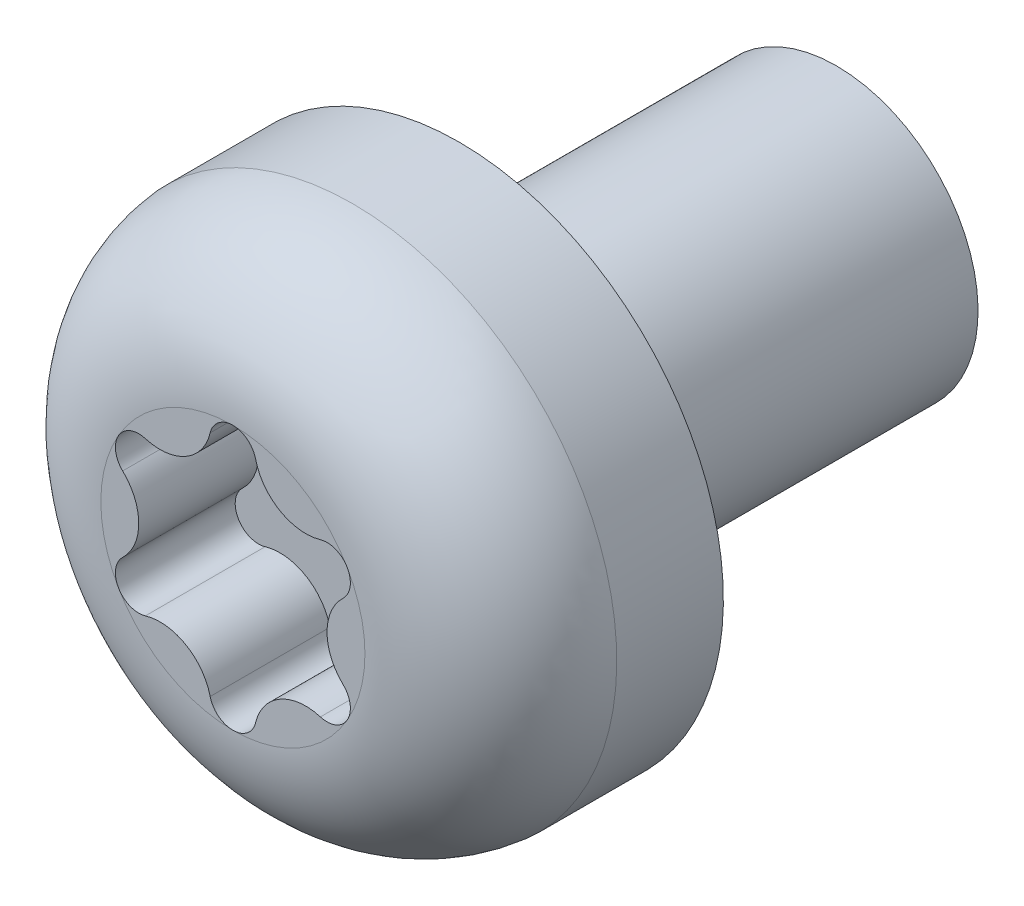
from build123d import *

# Parameters (mm, degrees)
ENL_V_MAT_EXTRU_1_DEPTH = 1.27


with BuildPart() as part:
    # Esquisse1 → Révolution1 (revolve)
    with BuildSketch(Plane(origin=(0, 0, 0), x_dir=(0, 0, -1), z_dir=(1, 0, 0))):
        with BuildLine():
            Line((-2.4, 0), (-2.4, 1.4))
            ThreePointArc((-2.4, 1.4), (-2.035195386, 2.345105814), (-1.13, 2.8))
            Line((-1.13, 2.8), (0, 2.8))
            Line((0, 2.8), (0, 1.5))
            Line((0, 1.5), (4, 1.5))
            Line((4, 1.5), (4, 0))
            Line((4, 0), (-2.4, 0))
        make_face()
    revolve(axis=Axis((0, 0, 2.4), (0, 0, 1)))

    # Esquisse2 → Enlèv. mat.-Extru.1 (cut)
    with BuildSketch(Plane.XY.offset(2.4)):
        with BuildLine():
            ThreePointArc((-0.240728142, 1.210222096), (0, 1.4), (0.240728142, 1.210222096))
            ThreePointArc((0.240728142, 1.210222096), (0.499017901, 0.864324358), (0.927719008, 0.813587734))
            ThreePointArc((0.927719008, 0.813587734), (1.212435565, 0.7), (1.16844715, 0.396634361))
            ThreePointArc((1.16844715, 0.396634361), (0.998035801, 0), (1.16844715, -0.396634361))
            ThreePointArc((1.16844715, -0.396634361), (1.212435565, -0.7), (0.927719008, -0.813587734))
            ThreePointArc((0.927719008, -0.813587734), (0.499017901, -0.864324358), (0.240728142, -1.210222096))
            ThreePointArc((0.240728142, -1.210222096), (0, -1.4), (-0.240728142, -1.210222096))
            ThreePointArc((-0.240728142, -1.210222096), (-0.499017901, -0.864324358), (-0.927719008, -0.813587734))
            ThreePointArc((-0.927719008, -0.813587734), (-1.212435565, -0.7), (-1.16844715, -0.396634361))
            ThreePointArc((-1.16844715, -0.396634361), (-0.998035801, 0), (-1.16844715, 0.396634361))
            ThreePointArc((-1.16844715, 0.396634361), (-1.212435565, 0.7), (-0.927719008, 0.813587734))
            ThreePointArc((-0.927719008, 0.813587734), (-0.499017901, 0.864324358), (-0.240728142, 1.210222096))
        make_face()
    extrude(amount=-ENL_V_MAT_EXTRU_1_DEPTH, mode=Mode.SUBTRACT)


solid = part.part
